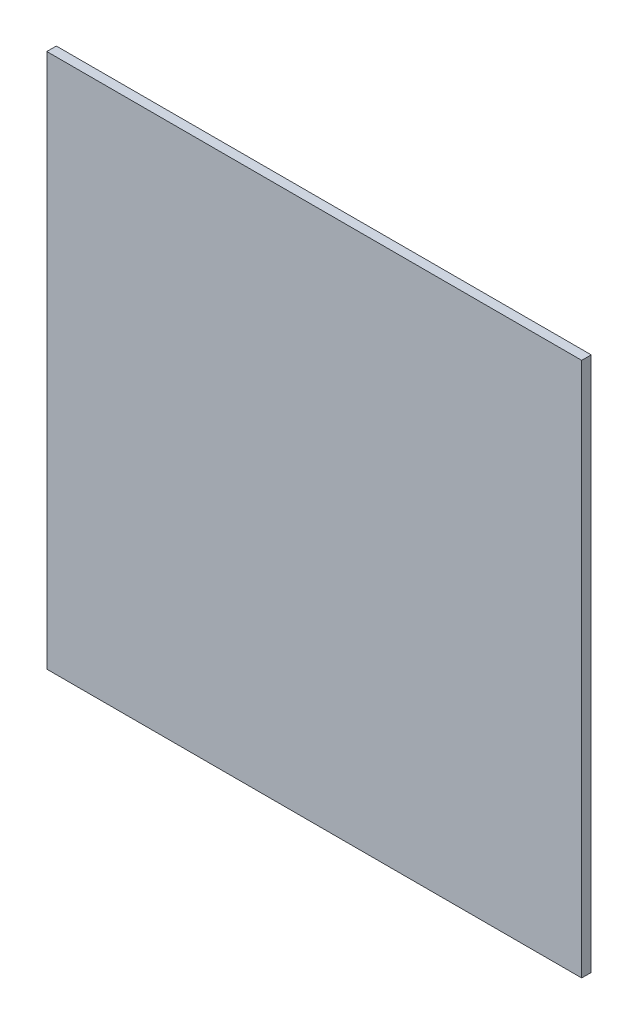
from build123d import *

# Parameters (mm, degrees)
SKIZZE1_W                       = 450
SKIZZE1_H                       = 450
AUFSATZ_LINEAR_AUSTRAGEN1_DEPTH = 8


with BuildPart() as part:
    # Skizze1 → Aufsatz-Linear austragen1 (new body)
    with BuildSketch(Plane.XY):
        Rectangle(SKIZZE1_W, SKIZZE1_H)
    extrude(amount=AUFSATZ_LINEAR_AUSTRAGEN1_DEPTH)


solid = part.part
